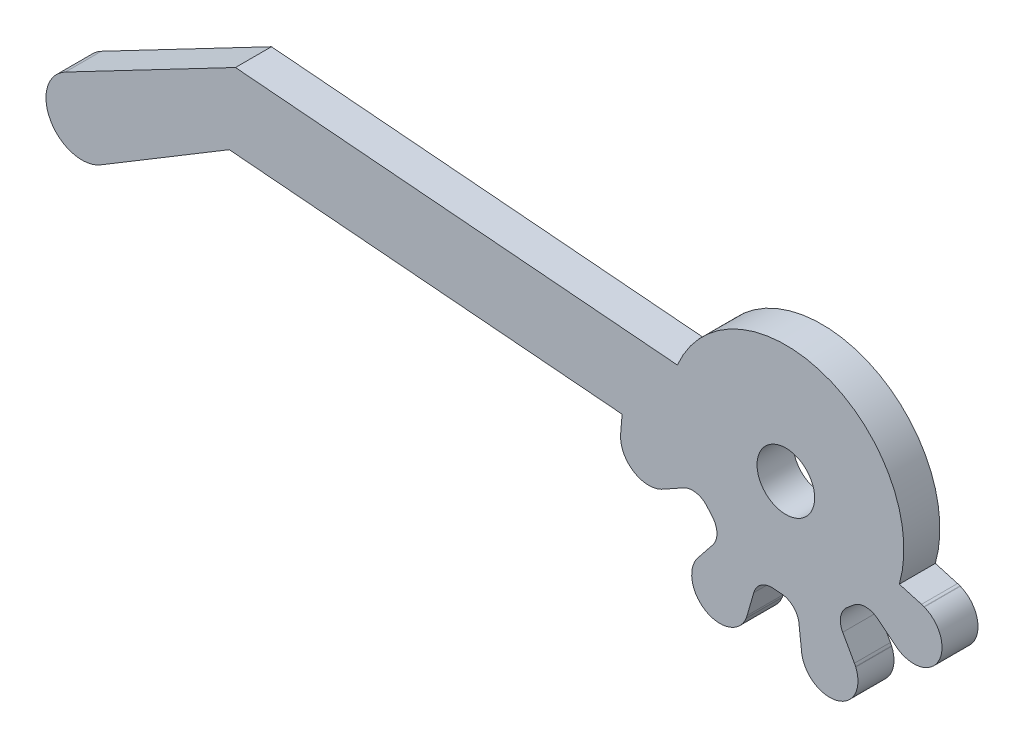
from build123d import *

# Parameters (mm, degrees)
MODEL_R                 = 2.4
SALIENTE_EXTRUIR1_DEPTH = 3


with BuildPart() as part:
    # Model → Saliente-Extruir1 (new body)
    with BuildSketch(Plane.XY):
        with BuildLine():
            Line((0.550846874, 14.545911472), (11.282662542, 21.007019657))
            Line((11.282662542, 21.007019657), (44.011748182, 18.287442361))
            Line((44.011748182, 18.287442361), (43.888957319, 16.809700693))
            ThreePointArc((43.888957319, 16.809700693), (44.855654521, 14.707163158), (47.155246022, 14.448229776))
            Line((47.155246022, 14.448229776), (47.182889346, 14.460182921))
            ThreePointArc((47.182889346, 14.460182921), (47.281916988, 14.506531358), (47.378685576, 14.557428234))
            Line((47.378685576, 14.557428234), (49.127384749, 15.529685066))
            ThreePointArc((49.127384749, 15.529685066), (50.19897968, 15.696696011), (51.122983719, 15.128871311))
            Line((51.122983719, 15.128871311), (51.504698759, 14.677971297))
            ThreePointArc((51.504698759, 14.677971297), (51.91223143, 13.672921311), (51.570646763, 12.643587416))
            Line((51.570646763, 12.643587416), (50.323105233, 11.079339262))
            ThreePointArc((50.323105233, 11.079339262), (50.256934954, 10.992298205), (50.194877883, 10.902278366))
            Line((50.194877883, 10.902278366), (50.178526203, 10.876986992))
            ThreePointArc((50.178526203, 10.876986992), (51.085631167, 7.518902031), (54.34625878, 8.730463665))
            Line((54.34625878, 8.730463665), (54.357353411, 8.758462597))
            ThreePointArc((54.357353411, 8.758462597), (54.394603234, 8.861259009), (54.427039433, 8.965674259))
            Line((54.427039433, 8.965674259), (54.976067079, 10.889680702))
            ThreePointArc((54.976067079, 10.889680702), (55.61570455, 11.765507317), (56.670586767, 12.017364142))
            Line((56.670586767, 12.017364142), (57.259334518, 11.968442975))
            ThreePointArc((57.259334518, 11.968442975), (58.258181294, 11.54593443), (58.744493436, 10.576548618))
            Line((58.744493436, 10.576548618), (58.96843884, 8.588313067))
            ThreePointArc((58.96843884, 8.588313067), (58.983196709, 8.479976292), (59.002969372, 8.372441678))
            Line((59.002969372, 8.372441678), (59.00929069, 8.342995592))
            ThreePointArc((59.00929069, 8.342995592), (62.025235409, 6.609891015), (63.474143857, 9.772206359))
            Line((63.474143857, 9.772206359), (63.462190711, 9.799849683))
            ThreePointArc((63.462190711, 9.799849683), (63.415842275, 9.898877325), (63.364945399, 9.995645912))
            Line((63.364945399, 9.995645912), (62.392688567, 11.744345086))
            ThreePointArc((62.392688567, 11.744345086), (62.225677622, 12.815940017), (62.793502322, 13.739944056))
            Line((62.793502322, 13.739944056), (63.244402336, 14.121659096))
            ThreePointArc((63.244402336, 14.121659096), (64.249452322, 14.529191767), (65.278786217, 14.187607099))
            Line((65.278786217, 14.187607099), (66.843034372, 12.940065573))
            ThreePointArc((66.843034372, 12.940065573), (66.930075429, 12.873895294), (67.020095268, 12.811838223))
            Line((67.020095268, 12.811838223), (67.045386643, 12.795486542))
            ThreePointArc((67.045386643, 12.795486542), (70.403471604, 13.702591507), (69.191909969, 16.963219119))
            Line((69.191909969, 16.963219119), (69.163911037, 16.974313751))
            ThreePointArc((69.163911037, 16.974313751), (69.061114626, 17.011563574), (68.956699375, 17.043999773))
            Line((68.956699375, 17.043999773), (67.107784068, 17.571599676))
            ThreePointArc((67.107784068, 17.571599676), (60.941730208, 29.535754633), (48.612503883, 24.136550776))
            Line((48.612503883, 24.136550776), (11.796901511, 27.195691428))
            Line((11.796901511, 27.195691428), (-2.378510761, 19.779467823))
            ThreePointArc((-2.378510761, 19.779467823), (-3.605636909, 15.656016384), (0.550846874, 14.545911472))
        make_face()
        with Locations((57.652706647, 20.269666987)):
            Circle(MODEL_R, mode=Mode.SUBTRACT)
    extrude(amount=SALIENTE_EXTRUIR1_DEPTH)


solid = part.part
